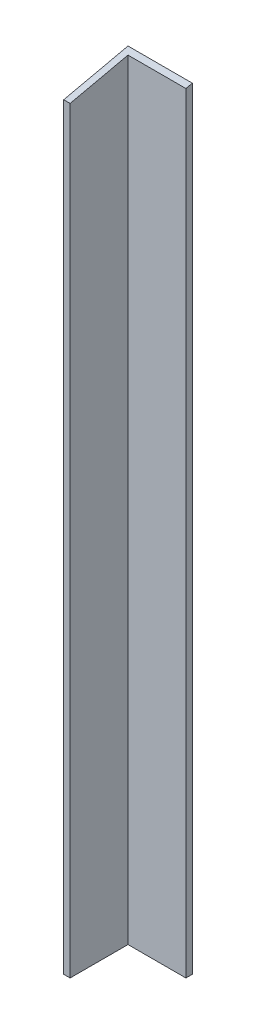
from build123d import *

# Parameters (mm, degrees)
SKETCH1_W           = 20
SKETCH1_H           = 240
BOSS_EXTRUDE1_DEPTH = 20
CUT_EXTRUDE1_DEPTH  = 20
SKETCH3_W           = 18
SKETCH3_H           = 18
CUT_EXTRUDE2_DEPTH  = 290


with BuildPart() as part:
    # Sketch1 → Boss-Extrude1 (new body)
    with BuildSketch(Plane.XY):
        with Locations((-51.462686567, -1.835820896)):
            Rectangle(SKETCH1_W, SKETCH1_H)
    extrude(amount=-BOSS_EXTRUDE1_DEPTH)

    # Sketch2 → Cut-Extrude1 (cut)
    with BuildSketch(Plane.ZY.offset(61.462686567)):
        Polygon((-20, 118.164179104), (0, 113.693649447), (0, 118.164179104), align=None)
    extrude(amount=-CUT_EXTRUDE1_DEPTH, mode=Mode.SUBTRACT)

    # Sketch3 → Cut-Extrude2 (cut)
    with BuildSketch(Plane.XZ.offset(121.835820896)):
        with Locations((-50.462686567, -9)):
            Rectangle(SKETCH3_W, SKETCH3_H)
    extrude(amount=-CUT_EXTRUDE2_DEPTH, mode=Mode.SUBTRACT)


solid = part.part
